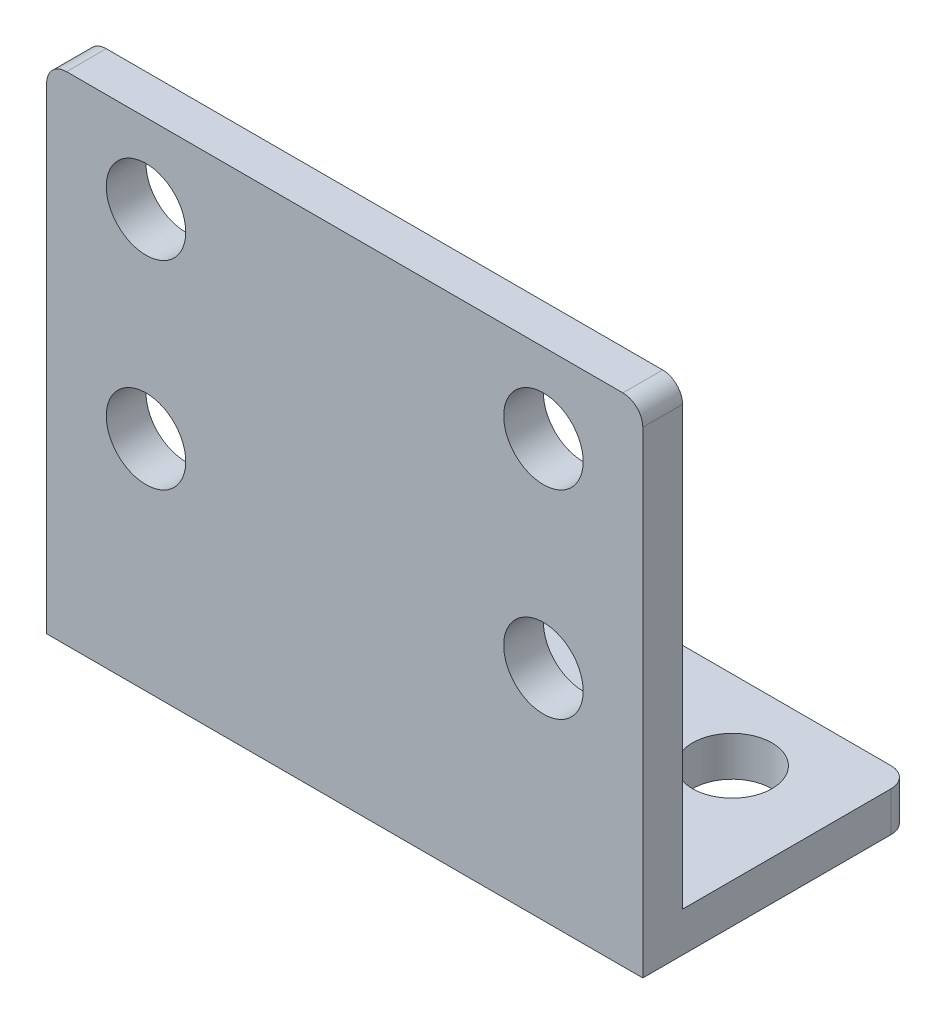
from build123d import *

# Parameters (mm, degrees)
BOSS_EXTRUDE1_DEPTH = 60
CUT_EXTRUDE3_REACH  = 29
SKETCH8_R           = 3.999999996
CUT_EXTRUDE4_REACH  = 52
SKETCH9_R           = 4.000000003
FILLET2_R           = 2


with BuildPart() as part:
    # Sketch1 → Boss-Extrude1 (new body)
    with BuildSketch(Plane(origin=(0, 0, 0), x_dir=(0, 0, -1), z_dir=(1, 0, 0))):
        Polygon((0, 0), (0, 50), (4, 50), (4, 4), (27, 4), (27, 0), align=None)
    extrude(amount=BOSS_EXTRUDE1_DEPTH)

    # Sketch8 → Cut-Extrude3 (cut, up to next)
    with BuildSketch(Plane.XY, mode=Mode.PRIVATE) as cut_extrude3_sk1:
        with Locations((10, 22)):
            Circle(SKETCH8_R)
    cut_extrude3_tool1 = extrude(cut_extrude3_sk1.sketch, amount=-CUT_EXTRUDE3_REACH, mode=Mode.PRIVATE) & part.part
    add(cut_extrude3_tool1.solids().sort_by_distance((10, 22, 0))[0], mode=Mode.SUBTRACT)
    # Sketch8 → Cut-Extrude3 (cut, up to next)
    with BuildSketch(Plane.XY, mode=Mode.PRIVATE) as cut_extrude3_sk2:
        with Locations((50, 22)):
            Circle(SKETCH8_R)
    cut_extrude3_tool2 = extrude(cut_extrude3_sk2.sketch, amount=-CUT_EXTRUDE3_REACH, mode=Mode.PRIVATE) & part.part
    add(cut_extrude3_tool2.solids().sort_by_distance((50, 22, 0))[0], mode=Mode.SUBTRACT)
    # Sketch8 → Cut-Extrude3 (cut, up to next)
    with BuildSketch(Plane.XY, mode=Mode.PRIVATE) as cut_extrude3_sk3:
        with Locations((50, 42)):
            Circle(SKETCH8_R)
    cut_extrude3_tool3 = extrude(cut_extrude3_sk3.sketch, amount=-CUT_EXTRUDE3_REACH, mode=Mode.PRIVATE) & part.part
    add(cut_extrude3_tool3.solids().sort_by_distance((50, 42, 0))[0], mode=Mode.SUBTRACT)
    # Sketch8 → Cut-Extrude3 (cut, up to next)
    with BuildSketch(Plane.XY, mode=Mode.PRIVATE) as cut_extrude3_sk4:
        with Locations((10, 42)):
            Circle(SKETCH8_R)
    cut_extrude3_tool4 = extrude(cut_extrude3_sk4.sketch, amount=-CUT_EXTRUDE3_REACH, mode=Mode.PRIVATE) & part.part
    add(cut_extrude3_tool4.solids().sort_by_distance((10, 42, 0))[0], mode=Mode.SUBTRACT)

    # Sketch9 → Cut-Extrude4 (cut, up to next)
    with BuildSketch(Plane.XZ, mode=Mode.PRIVATE) as cut_extrude4_sk1:
        with Locations((50, -19)):
            Circle(SKETCH9_R)
    cut_extrude4_tool1 = extrude(cut_extrude4_sk1.sketch, amount=-CUT_EXTRUDE4_REACH, mode=Mode.PRIVATE) & part.part
    add(cut_extrude4_tool1.solids().sort_by_distance((50, 0, -19))[0], mode=Mode.SUBTRACT)
    # Sketch9 → Cut-Extrude4 (cut, up to next)
    with BuildSketch(Plane.XZ, mode=Mode.PRIVATE) as cut_extrude4_sk2:
        with Locations((10, -19)):
            Circle(SKETCH9_R)
    cut_extrude4_tool2 = extrude(cut_extrude4_sk2.sketch, amount=-CUT_EXTRUDE4_REACH, mode=Mode.PRIVATE) & part.part
    add(cut_extrude4_tool2.solids().sort_by_distance((10, 0, -19))[0], mode=Mode.SUBTRACT)

    # Fillet2
    fillet2_edges = [part.edges().sort_by_distance(p)[0] for p in [
        (60, 50, -2),
        (0, 50, -2),
        (60, 2, -27),
        (0, 2, -27),
    ]]
    fillet(fillet2_edges, radius=FILLET2_R)


solid = part.part
